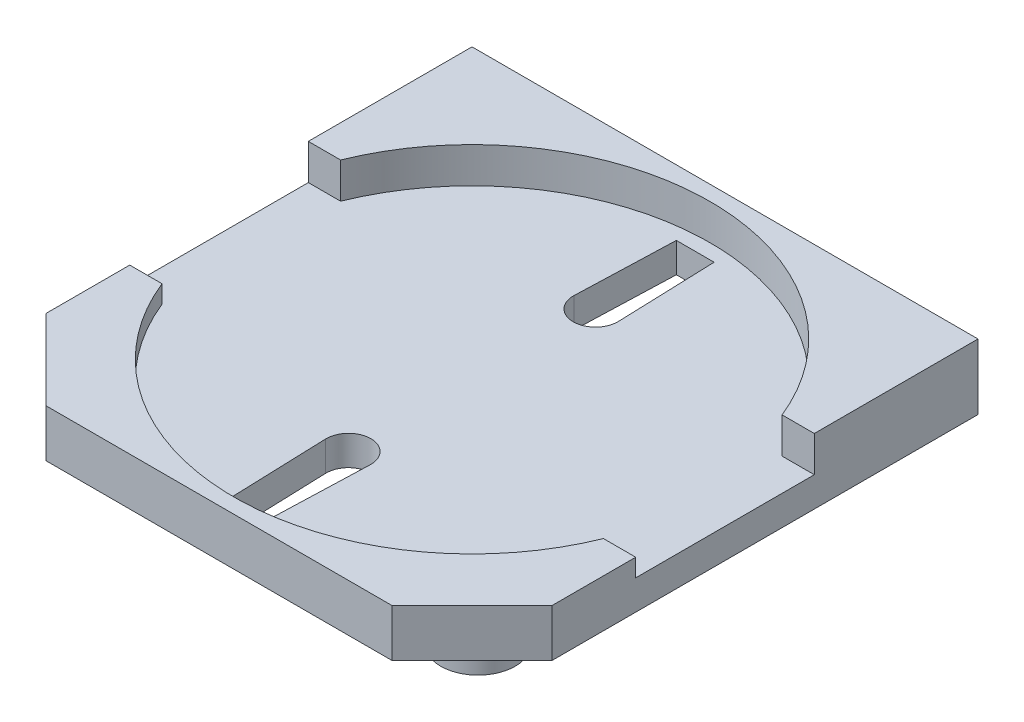
from build123d import *

# Parameters (mm, degrees)
SKETCH1_W           = 17
SKETCH1_H           = 17
BOSS_EXTRUDE1_DEPTH = 3.5
CUT_EXTRUDE1_DEPTH  = 4.5
CUT_EXTRUDE2_DEPTH  = 0.6
SKETCH5_W           = 17
SKETCH5_H           = 6
CUT_EXTRUDE3_DEPTH  = 0.6
SKETCH6_R           = 8
CUT_EXTRUDE4_DEPTH  = 1.2
SKETCH7_OUTSIDE_W   = 23.86
SKETCH7_OUTSIDE_H   = 23.86
SKETCH7_OUTSIDE_R   = 1.25
CUT_EXTRUDE5_DEPTH  = 1.3
CUT_EXTRUDE6_DEPTH  = 1
BOSS_EXTRUDE4_DEPTH = 1


with BuildPart() as part:
    # Sketch1 → Boss-Extrude1 (new body)
    with BuildSketch(Plane(origin=(0, 0, 0), x_dir=(1, 0, 0), z_dir=(0, 1, 0))):
        Rectangle(SKETCH1_W, SKETCH1_H)
    extrude(amount=BOSS_EXTRUDE1_DEPTH)

    # Sketch2 → Cut-Extrude1 (cut, through all)
    with BuildSketch(Plane(origin=(0, 3.5, 0), x_dir=(1, 0, 0), z_dir=(0, 1, 0))):
        Polygon((-8.5, -5.812994231), (-5.812994231, -8.5), (-8.5, -8.5), align=None)
    cut_extrude1 = extrude(amount=-CUT_EXTRUDE1_DEPTH, mode=Mode.SUBTRACT)

    # Mirror1: Cut-Extrude1 across plane
    add(cut_extrude1.mirror(Plane(origin=(0, 0, 0), x_dir=(0, 0, 1), z_dir=(1, 0, 0))), mode=Mode.SUBTRACT)

    # Sketch3 → Cut-Extrude2 (cut)
    with BuildSketch(Plane(origin=(0, 3.5, 0), x_dir=(1, 0, 0), z_dir=(0, 1, 0))):
        Polygon((-8.5, 3), (8.5, 3), (8.5, -5.812994231), (5.812994231, -8.5), (-5.812994231, -8.5), (-8.5, -5.812994231), align=None)
    extrude(amount=-CUT_EXTRUDE2_DEPTH, mode=Mode.SUBTRACT)

    # Sketch5 → Cut-Extrude3 (cut)
    with BuildSketch(Plane(origin=(0, 2.9, 0), x_dir=(1, 0, 0), z_dir=(0, 1, 0))):
        Rectangle(SKETCH5_W, SKETCH5_H)
    extrude(amount=-CUT_EXTRUDE3_DEPTH, mode=Mode.SUBTRACT)

    # Sketch6 → Cut-Extrude4 (cut)
    with BuildSketch(Plane(origin=(0, 3.5, 0), x_dir=(1, 0, 0), z_dir=(0, 1, 0))):
        Circle(SKETCH6_R)
    extrude(amount=-CUT_EXTRUDE4_DEPTH, mode=Mode.SUBTRACT)

    # Sketch7 outside → Cut-Extrude5 (cut)
    with BuildSketch(Plane.XZ):
        Rectangle(SKETCH7_OUTSIDE_W, SKETCH7_OUTSIDE_H)
        with Locations((-5.5, -6.20094747)):
            Circle(SKETCH7_OUTSIDE_R, mode=Mode.SUBTRACT)
        with Locations((-5.5, 5.29905253)):
            Circle(SKETCH7_OUTSIDE_R, mode=Mode.SUBTRACT)
        with Locations((5.5, 5.29905253)):
            Circle(SKETCH7_OUTSIDE_R, mode=Mode.SUBTRACT)
        with Locations((5.5, -6.20094747)):
            Circle(SKETCH7_OUTSIDE_R, mode=Mode.SUBTRACT)
    extrude(amount=-CUT_EXTRUDE5_DEPTH, mode=Mode.SUBTRACT)

    # Sketch8 → Cut-Extrude6 (cut)
    with BuildSketch(Plane.XZ.offset(-1.3)):
        with BuildLine():
            Line((-0.6, -8.5), (0.6, -8.5))
            Line((0.6, -8.5), (0.749551834, -4.175923885))
            ThreePointArc((0.749551834, -4.175923885), (0, -3.4), (-0.749551834, -4.175923885))
            Line((-0.749551834, -4.175923885), (-0.6, -8.5))
        make_face()
    cut_extrude6 = extrude(amount=-CUT_EXTRUDE6_DEPTH, mode=Mode.SUBTRACT)

    # Mirror2: Cut-Extrude6 across plane
    add(cut_extrude6.mirror(Plane.XY), mode=Mode.SUBTRACT)

    # Sketch11 → Boss-Extrude4 (add)
    with BuildSketch(Plane.XZ.offset(-1.3)):
        Polygon((-0.6, -8.5), (0.6, -8.5), (0.634585847, -7.5), (-0.634585847, -7.5), align=None)
    boss_extrude4 = extrude(amount=-BOSS_EXTRUDE4_DEPTH)

    # Mirror3: Boss-Extrude4 across plane
    add(boss_extrude4.mirror(Plane.XY))


solid = part.part
